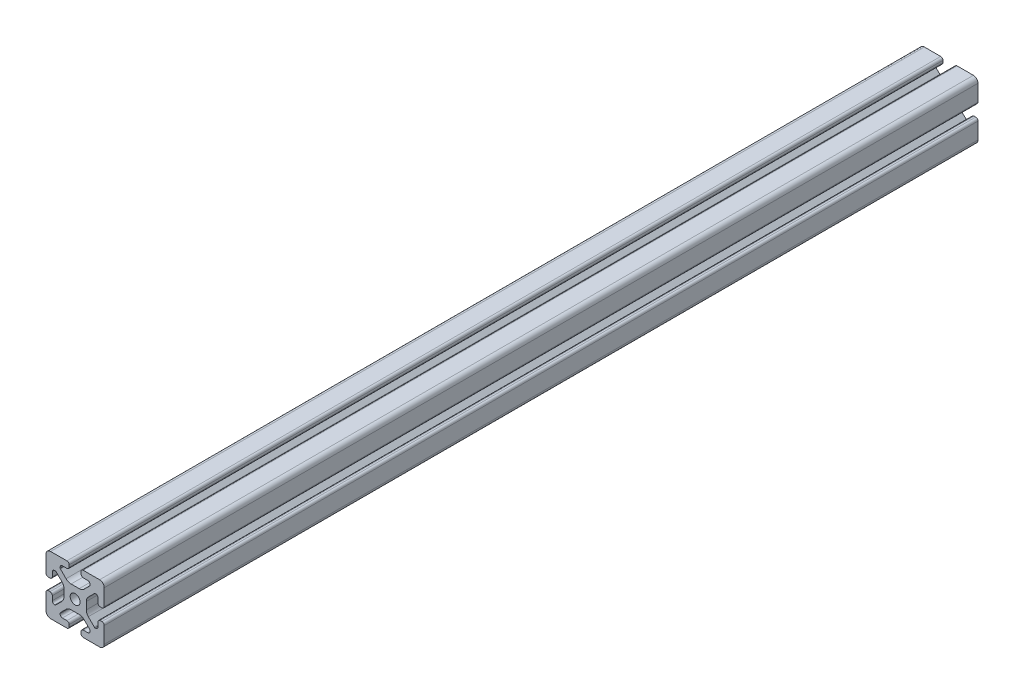
from build123d import *

# Parameters (mm, degrees)
SKETCH1_R           = 3.4
BOSS_EXTRUDE1_DEPTH = 600


with BuildPart() as part:
    # Sketch1 → Boss-Extrude1 (new body)
    with BuildSketch(Plane.XY):
        with BuildLine():
            Line((-8.715, -15.524615034), (-5.63, -15.524615034))
            ThreePointArc((-5.63, -15.524615034), (-4.519842354, -15.984457388), (-4.06, -17.094615034))
            Line((-4.06, -17.094615034), (-4.06, -18.43))
            ThreePointArc((-4.06, -18.43), (-4.519842354, -19.540157646), (-5.63, -20))
            Line((-5.63, -20), (-16.674615034, -20))
            ThreePointArc((-16.674615034, -20), (-18.951578385, -19.194274381), (-20, -17.018368134))
            Line((-20, -17.018368134), (-20, -5.757918808))
            ThreePointArc((-20, -5.757918808), (-19.564709668, -4.603883664), (-18.43, -4.120449326))
            Line((-18.43, -4.120449326), (-17.248545805, -4.120449326))
            ThreePointArc((-17.248545805, -4.120449326), (-16.114784845, -4.604407881), (-15.67999625, -5.757919334))
            Line((-15.67999625, -5.757919334), (-15.67999625, -8.715399492))
            ThreePointArc((-15.67999625, -8.715399492), (-15.220153896, -9.825557139), (-14.10999625, -10.285399492))
            Line((-14.10999625, -10.285399492), (-13.816903094, -10.285399492))
            ThreePointArc((-13.816903094, -10.285399492), (-13.526063686, -10.227547937), (-13.279501941, -10.062800646))
            Line((-13.279501941, -10.062800646), (-9.076242789, -5.859541495))
            ThreePointArc((-9.076242789, -5.859541495), (-8.046572221, -4.318530588), (-7.685, -2.500784284))
            Line((-7.685, -2.500784284), (-7.685, 2.500784284))
            ThreePointArc((-7.685, 2.500784284), (-8.046572221, 4.318530588), (-9.076242789, 5.859541495))
            Line((-9.076242789, 5.859541495), (-13.040489136, 9.823787841))
            ThreePointArc((-13.040489136, 9.823787841), (-13.354224618, 10.012729352), (-13.71989919, 10.033001362))
            Line((-13.71989919, 10.033001362), (-14.05520779, 10.044710596))
            ThreePointArc((-14.05520779, 10.044710596), (-15.200613642, 9.605030484), (-15.68, 8.475666998))
            Line((-15.68, 8.475666998), (-15.68, 5.572979049))
            ThreePointArc((-15.68, 5.572979049), (-16.139842354, 4.462821403), (-17.25, 4.002979049))
            Line((-17.25, 4.002979049), (-18.43, 4.002979049))
            ThreePointArc((-18.43, 4.002979049), (-19.540157646, 4.462821403), (-20, 5.572979049))
            Line((-20, 5.572979049), (-20, 13.004526564))
            Line((-20, 13.004526564), (-20, 16.83))
            ThreePointArc((-20, 16.83), (-19.071528496, 19.071528496), (-16.83, 20))
            Line((-16.83, 20), (-5.63, 20))
            ThreePointArc((-5.63, 20), (-4.519842354, 19.540157646), (-4.06, 18.43))
            Line((-4.06, 18.43), (-4.06, 17.094615034))
            ThreePointArc((-4.06, 17.094615034), (-4.519842354, 15.984457388), (-5.63, 15.524615034))
            Line((-5.63, 15.524615034), (-8.715, 15.524615034))
            ThreePointArc((-8.715, 15.524615034), (-9.825157646, 15.06477268), (-10.285, 13.954615034))
            Line((-10.285, 13.954615034), (-10.285, 13.492503602))
            ThreePointArc((-10.285, 13.492503602), (-10.227148445, 13.201664194), (-10.062401154, 12.955102448))
            Line((-10.062401154, 12.955102448), (-6.217092793, 9.109794088))
            ThreePointArc((-6.217092793, 9.109794088), (-4.63891877, 8.055291919), (-2.777335583, 7.685))
            Line((-2.777335583, 7.685), (2.777335583, 7.685))
            ThreePointArc((2.777335583, 7.685), (4.63891877, 8.055291919), (6.217092793, 9.109794088))
            Line((6.217092793, 9.109794088), (10.062401154, 12.955102448))
            ThreePointArc((10.062401154, 12.955102448), (10.227148445, 13.201664194), (10.285, 13.492503602))
            Line((10.285, 13.492503602), (10.285, 13.954615034))
            ThreePointArc((10.285, 13.954615034), (9.825157646, 15.06477268), (8.715, 15.524615034))
            Line((8.715, 15.524615034), (5.63, 15.524615034))
            ThreePointArc((5.63, 15.524615034), (4.519842354, 15.984457388), (4.06, 17.094615034))
            Line((4.06, 17.094615034), (4.06, 18.43))
            ThreePointArc((4.06, 18.43), (4.519842354, 19.540157646), (5.63, 20))
            Line((5.63, 20), (12.979635074, 20))
            Line((12.979635074, 20), (16.83, 20))
            ThreePointArc((16.83, 20), (19.071528496, 19.071528496), (20, 16.83))
            Line((20, 16.83), (20, 13.001098436))
            Line((20, 13.001098436), (20, 5.630000526))
            ThreePointArc((20, 5.630000526), (19.540157646, 4.519842879), (18.43, 4.060000526))
            Line((18.43, 4.060000526), (17.24999625, 4.060000526))
            ThreePointArc((17.24999625, 4.060000526), (16.139838603, 4.519842879), (15.67999625, 5.630000526))
            Line((15.67999625, 5.630000526), (15.67999625, 8.715399492))
            ThreePointArc((15.67999625, 8.715399492), (15.220153896, 9.825557139), (14.10999625, 10.285399492))
            Line((14.10999625, 10.285399492), (13.816903094, 10.285399492))
            ThreePointArc((13.816903094, 10.285399492), (13.526063686, 10.227547937), (13.279501941, 10.062800646))
            Line((13.279501941, 10.062800646), (9.076242789, 5.859541495))
            ThreePointArc((9.076242789, 5.859541495), (8.046572221, 4.318530588), (7.685, 2.500784284))
            Line((7.685, 2.500784284), (7.685, -2.500784284))
            ThreePointArc((7.685, -2.500784284), (8.046572221, -4.318530588), (9.076242789, -5.859541495))
            Line((9.076242789, -5.859541495), (13.163657296, -9.946956002))
            ThreePointArc((13.163657296, -9.946956002), (13.35903797, -10.160433474), (13.6200547, -10.285399492))
            Line((13.6200547, -10.285399492), (14.10999625, -10.285399492))
            ThreePointArc((14.10999625, -10.285399492), (15.220153896, -9.825557139), (15.67999625, -8.715399492))
            Line((15.67999625, -8.715399492), (15.67999625, -5.630000526))
            ThreePointArc((15.67999625, -5.630000526), (16.139838603, -4.519842879), (17.24999625, -4.060000526))
            Line((17.24999625, -4.060000526), (18.43, -4.060000526))
            ThreePointArc((18.43, -4.060000526), (19.540157646, -4.519842879), (20, -5.630000526))
            Line((20, -5.630000526), (20, -16.83))
            ThreePointArc((20, -16.83), (19.071528496, -19.071528496), (16.83, -20))
            Line((16.83, -20), (13, -20))
            Line((13, -20), (5.63, -20))
            ThreePointArc((5.63, -20), (4.519842354, -19.540157646), (4.06, -18.43))
            Line((4.06, -18.43), (4.06, -17.094615034))
            ThreePointArc((4.06, -17.094615034), (4.519842354, -15.984457388), (5.63, -15.524615034))
            Line((5.63, -15.524615034), (8.715, -15.524615034))
            ThreePointArc((8.715, -15.524615034), (9.825157646, -15.06477268), (10.285, -13.954615034))
            Line((10.285, -13.954615034), (10.285, -13.492503602))
            ThreePointArc((10.285, -13.492503602), (10.227148445, -13.201664194), (10.062401154, -12.955102448))
            Line((10.062401154, -12.955102448), (6.217092793, -9.109794088))
            ThreePointArc((6.217092793, -9.109794088), (4.63891877, -8.055291919), (2.777335583, -7.685))
            Line((2.777335583, -7.685), (-2.777335583, -7.685))
            ThreePointArc((-2.777335583, -7.685), (-4.63891877, -8.055291919), (-6.217092793, -9.109794088))
            Line((-6.217092793, -9.109794088), (-10.062401154, -12.955102448))
            ThreePointArc((-10.062401154, -12.955102448), (-10.227148445, -13.201664194), (-10.285, -13.492503602))
            Line((-10.285, -13.492503602), (-10.285, -13.954615034))
            ThreePointArc((-10.285, -13.954615034), (-9.825157646, -15.06477268), (-8.715, -15.524615034))
        make_face()
        Circle(SKETCH1_R, mode=Mode.SUBTRACT)
    extrude(amount=BOSS_EXTRUDE1_DEPTH)


solid = part.part
